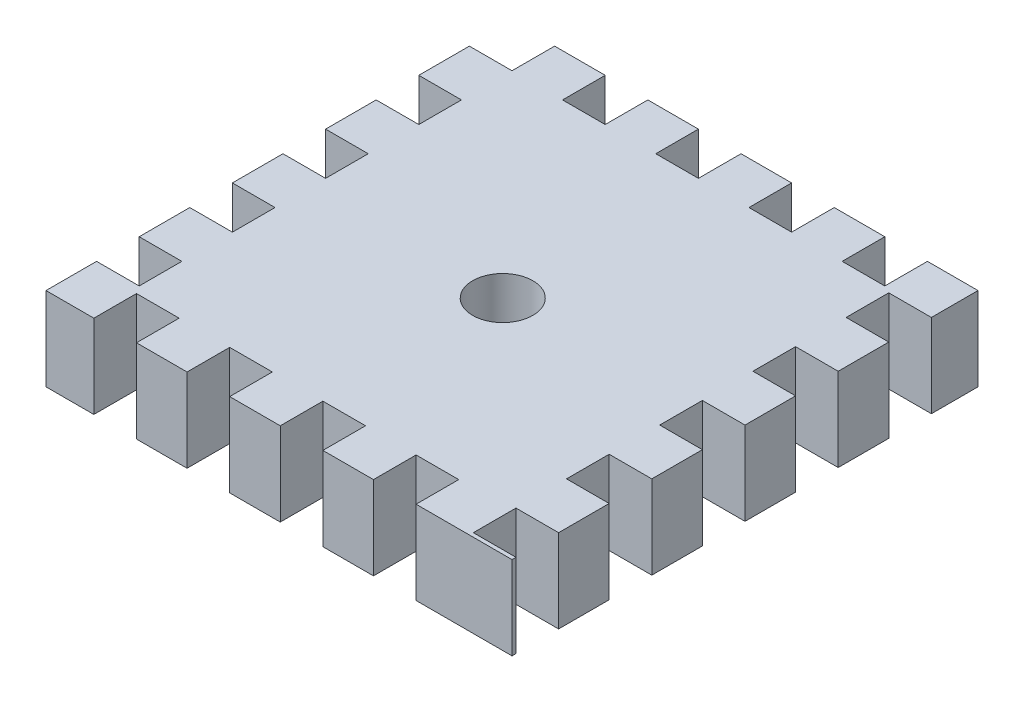
from build123d import *

# Parameters (mm, degrees)
SKETCH3_W                = 50.8
SKETCH3_H                = 50.8
BOSS_EXTRUDE5_DEPTH      = 4.572
BOSS_EXTRUDE5_DEPTH_BACK = 4.5212
SKETCH4_W                = 4.6482
SKETCH4_H                = 4.6482
CUT_EXTRUDE4_DEPTH       = 9.0932
SKETCH10_R               = 3.280660975
CUT_EXTRUDE9_DEPTH       = 5.08
SKETCH9_W                = 4.6482
SKETCH9_H                = 4.6482
CUT_EXTRUDE10_DEPTH      = 9.144
LPATTERN1_COUNT          = 5
LPATTERN1_PITCH          = 10.16
LPATTERN2_COUNT          = 5
LPATTERN2_PITCH          = 10.16
LPATTERN3_COUNT          = 5
LPATTERN3_PITCH          = 10.16
SKETCH13_W               = 4.6482
SKETCH13_H               = 4.6482
CUT_EXTRUDE11_DEPTH      = 9.144
LPATTERN4_COUNT          = 4
LPATTERN4_PITCH          = 10.16


with BuildPart() as part:
    # Sketch3 → Boss-Extrude5 (new body, two sides)
    with BuildSketch(Plane(origin=(0, 0, 0), x_dir=(1, 0, 0), z_dir=(0, 1, 0))) as boss_extrude5_sk:
        with Locations((46.091507602, -76.594393473)):
            Rectangle(SKETCH3_W, SKETCH3_H)
    extrude(amount=BOSS_EXTRUDE5_DEPTH)
    extrude(boss_extrude5_sk.sketch, amount=-BOSS_EXTRUDE5_DEPTH_BACK)

    # Sketch4 → Cut-Extrude4 (cut)
    with BuildSketch(Plane(origin=(0, 4.572, 0), x_dir=(1, 0, 0), z_dir=(0, 1, 0))):
        with Locations((23.015607602, -53.518493473)):
            Rectangle(SKETCH4_W, SKETCH4_H)
    cut_extrude4 = extrude(amount=-CUT_EXTRUDE4_DEPTH, mode=Mode.SUBTRACT)

    # Sketch10 → Cut-Extrude9 (cut)
    with BuildSketch(Plane(origin=(0, 4.572, 0), x_dir=(1, 0, 0), z_dir=(0, 1, 0))):
        with Locations(Location((46.297206245, -77.809978732, 0), (0, 0, 270))):  # turned: the seam where the file's is
            Circle(SKETCH10_R)
    extrude(amount=-CUT_EXTRUDE9_DEPTH, mode=Mode.SUBTRACT)

    # Sketch9 → Cut-Extrude10 (cut)
    with BuildSketch(Plane(origin=(0, 4.572, 0), x_dir=(1, 0, 0), z_dir=(0, 1, 0))):
        with Locations((69.167407602, -58.59849342)):
            Rectangle(SKETCH9_W, SKETCH9_H)
    cut_extrude10 = extrude(amount=-CUT_EXTRUDE10_DEPTH, mode=Mode.SUBTRACT)

    # LPattern1: Cut-Extrude4 ×5
    with Locations(*[(0, 0, i * LPATTERN1_PITCH) for i in range(1, LPATTERN1_COUNT)]):
        add(cut_extrude4, mode=Mode.SUBTRACT)

    # LPattern2: Cut-Extrude10 ×5
    with Locations(*[(0, 0, i * LPATTERN2_PITCH) for i in range(1, LPATTERN2_COUNT)]):
        add(cut_extrude10, mode=Mode.SUBTRACT)

    # LPattern3: Cut-Extrude4 ×5
    with Locations(*[(i * LPATTERN3_PITCH, 0, 0) for i in range(1, LPATTERN3_COUNT)]):
        add(cut_extrude4, mode=Mode.SUBTRACT)

    # Sketch13 → Cut-Extrude11 (cut)
    with BuildSketch(Plane(origin=(0, 4.572, 0), x_dir=(1, 0, 0), z_dir=(0, 1, 0))):
        with Locations((28.2321, -99.670293473)):
            Rectangle(SKETCH13_W, SKETCH13_H)
    cut_extrude11 = extrude(amount=-CUT_EXTRUDE11_DEPTH, mode=Mode.SUBTRACT)

    # LPattern4: Cut-Extrude11 ×4
    with Locations(*[(i * LPATTERN4_PITCH, 0, 0) for i in range(1, LPATTERN4_COUNT)]):
        add(cut_extrude11, mode=Mode.SUBTRACT)


solid = part.part
